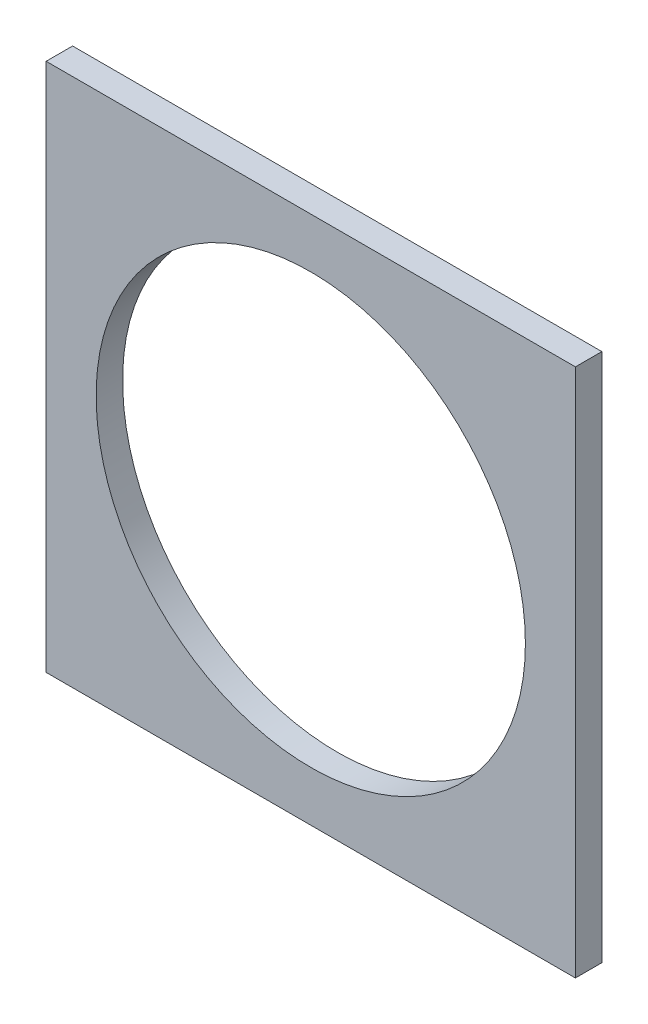
from build123d import *

# Parameters (mm, degrees)
SKETCH1_W           = 127
SKETCH1_H           = 127
BOSS_EXTRUDE1_DEPTH = 6.35
CUT_EXTRUDE1_REACH  = 8.35
SKETCH2_R           = 51.5


with BuildPart() as part:
    # Sketch1 → Boss-Extrude1 (new body)
    with BuildSketch(Plane.XY):
        Rectangle(SKETCH1_W, SKETCH1_H)
    extrude(amount=BOSS_EXTRUDE1_DEPTH)

    # Sketch2 → Cut-Extrude1 (cut, up to next)
    with BuildSketch(Plane.XY.offset(6.35), mode=Mode.PRIVATE) as cut_extrude1_sk1:
        Circle(SKETCH2_R)
    cut_extrude1_tool1 = extrude(cut_extrude1_sk1.sketch, amount=-CUT_EXTRUDE1_REACH, mode=Mode.PRIVATE) & part.part
    add(cut_extrude1_tool1.solids().sort_by_distance((0, 0, 6.35))[0], mode=Mode.SUBTRACT)


solid = part.part
